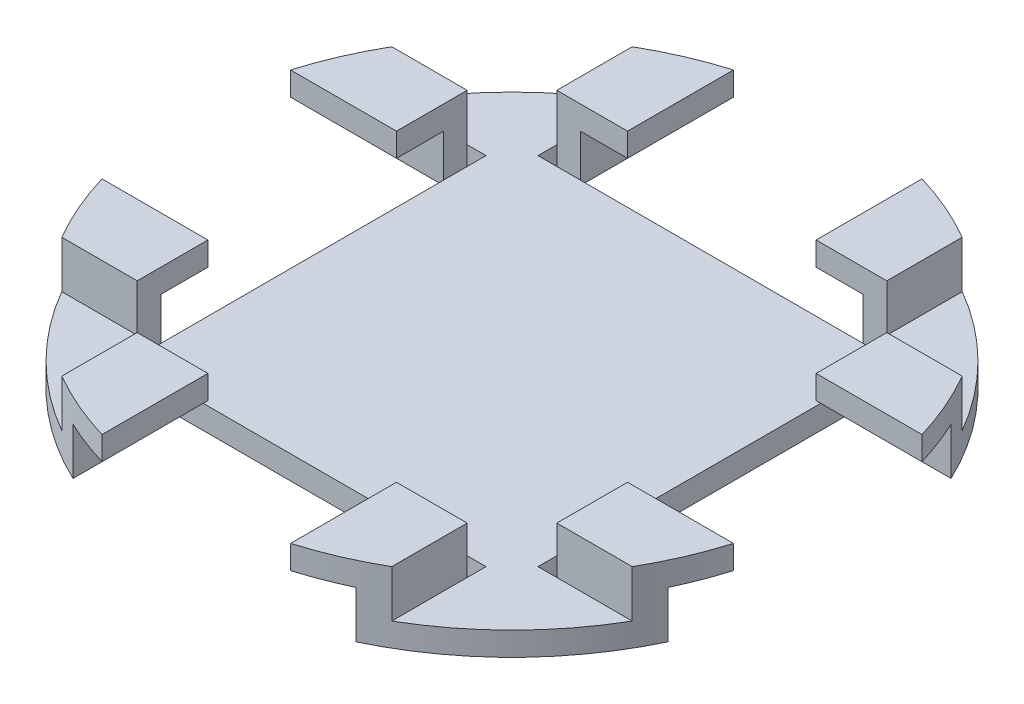
from build123d import *

# Parameters (mm, degrees)
SKETCH1_R          = 88.773
BASE_DEPTH         = 6.35
STOPPER_DEPTH      = 12.7
STOPPER_START      = -6.35
STOPPER_GAP_DEPTH  = 13.7
OVERHANG_CUT_DEPTH = 26.416
CIRPATTERN1_COUNT  = 4


with BuildPart() as part:
    # Sketch1 → Base (new body)
    with BuildSketch(Plane(origin=(0, 0, 0), x_dir=(1, 0, 0), z_dir=(0, 1, 0))):
        Circle(SKETCH1_R)
    extrude(amount=BASE_DEPTH)

    # Sketch2 → Stopper (add)
    with BuildSketch(Plane(origin=(0, 6.35, 0), x_dir=(1, 0, 0), z_dir=(0, 1, 0))):
        with BuildLine():
            Line((-44.45, -76.842976445), (-44.45, -51.442976445))
            Line((-44.45, -51.442976445), (0, -51.442976445))
            Line((0, -51.442976445), (44.45, -51.442976445))
            Line((44.45, -51.442976445), (44.45, -76.842976445))
            ThreePointArc((44.45, -76.842976445), (23.011562105, -85.73863504), (0, -88.773))
            ThreePointArc((0, -88.773), (-23.011562105, -85.73863504), (-44.45, -76.842976445))
        make_face()
    stopper = extrude(amount=STOPPER_DEPTH)

    # Sketch5 → Stopper Gap (cut, through all)
    with BuildSketch(Plane(origin=(0, 19.05, 0), x_dir=(1, 0, 0), z_dir=(0, 1, 0)).offset(STOPPER_START)):
        with BuildLine():
            Line((-38.10000012, -80.181266639), (-38.10000012, -51.442976445))
            Line((-38.10000012, -51.442976445), (-1.2e-07, -51.442976445))
            Line((-1.2e-07, -51.442976445), (38.09999988, -51.442976445))
            Line((38.09999988, -51.442976445), (38.10000012, -80.181266639))
            ThreePointArc((38.10000012, -80.181266639), (19.528363291, -86.598432758), (0, -88.773))
            ThreePointArc((0, -88.773), (-19.528363291, -86.598432758), (-38.10000012, -80.181266639))
        make_face()
    stopper_gap = extrude(amount=-STOPPER_GAP_DEPTH, mode=Mode.SUBTRACT)

    # Sketch6 → Overhang cut (cut)
    with BuildSketch(Plane(origin=(0, 19.05, 0), x_dir=(1, 0, 0), z_dir=(0, 1, 0))):
        with BuildLine():
            Line((-25.4, -51.442976445), (0, -51.442976445))
            Line((0, -51.442976445), (25.4, -51.442976445))
            Line((25.4, -51.442976445), (44.45, -51.442976445))
            Line((44.45, -51.442976445), (44.45, -56.522976445))
            Line((44.45, -56.522976445), (25.4, -56.522976445))
            Line((25.4, -56.522976445), (25.4, -85.06165722))
            ThreePointArc((25.4, -85.06165722), (12.834855523, -87.840264188), (0, -88.773))
            ThreePointArc((0, -88.773), (-12.834855523, -87.840264188), (-25.4, -85.06165722))
            Line((-25.4, -85.06165722), (-25.4, -56.522976445))
            Line((-25.4, -56.522976445), (-44.45, -56.522976445))
            Line((-44.45, -56.522976445), (-44.45, -51.442976445))
            Line((-44.45, -51.442976445), (-25.4, -51.442976445))
        make_face()
    overhang_cut = extrude(amount=-OVERHANG_CUT_DEPTH, mode=Mode.SUBTRACT)

    # CirPattern1: Stopper, Stopper Gap, Overhang cut ×4 about axis
    cirpattern1_axis = Axis((0, 0, 0), (0, 1, 0))
    for i in range(1, CIRPATTERN1_COUNT):
        add(stopper.rotate(cirpattern1_axis, i * 360 / CIRPATTERN1_COUNT))
        add(stopper_gap.rotate(cirpattern1_axis, i * 360 / CIRPATTERN1_COUNT), mode=Mode.SUBTRACT)
        add(overhang_cut.rotate(cirpattern1_axis, i * 360 / CIRPATTERN1_COUNT), mode=Mode.SUBTRACT)


solid = part.part
